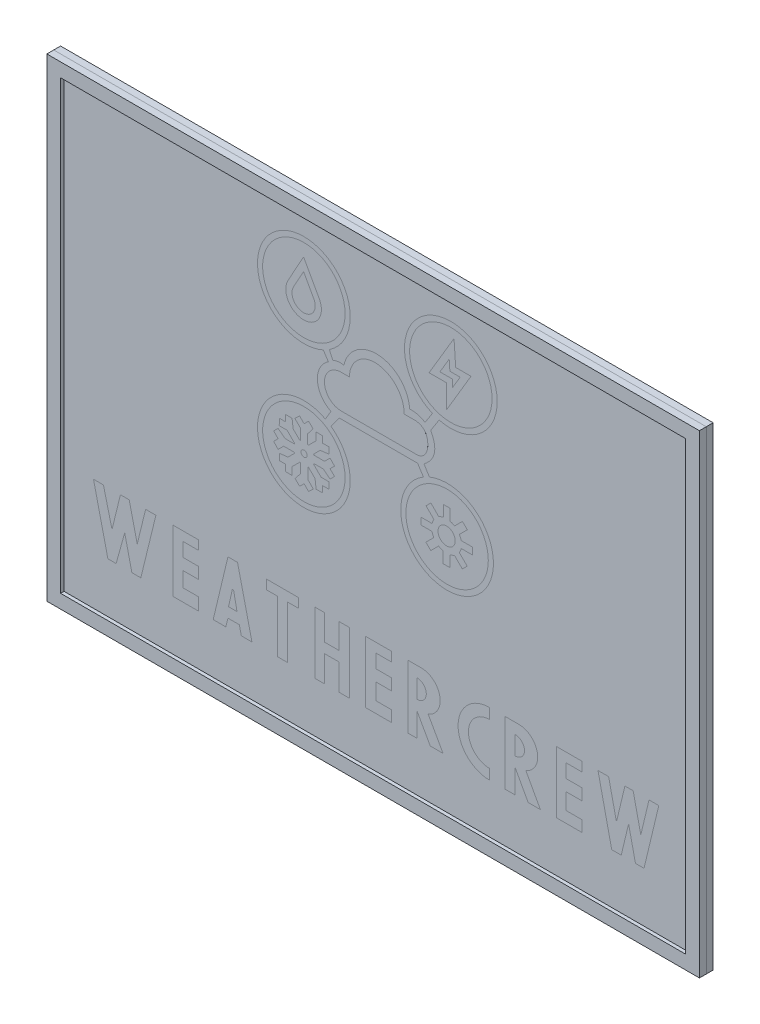
from build123d import *

# Parameters (mm, degrees)
SKETCH2_W              = 95
SKETCH2_H              = 69
BOSS_EXTRUDE1_DEPTH    = 10
SKETCH6_R              = 6.75
SKETCH6_R_2            = 6
CUT_EXTRUDE2_DEPTH     = 2
CUT_EXTRUDE3_DEPTH     = 2
CUT_EXTRUDE4_DEPTH     = 2
CUT_EXTRUDE5_DEPTH     = 2
SKETCH10_R             = 0.450714804
CUT_EXTRUDE6_DEPTH     = 2
SKETCH11_R             = 1.253958972
CUT_EXTRUDE7_DEPTH     = 2
CUT_EXTRUDE8_DEPTH     = 2
CUT_EXTRUDE9_DEPTH     = 2
BOSS_EXTRUDE2_DEPTH    = 2
SKETCH15_W             = 91
SKETCH15_H             = 65
CUT_EXTRUDE10_DEPTH    = 1
SKETCH16_W             = 95
SKETCH16_H             = 69
CUT_EXTRUDE11_DEPTH    = 7.5
SKETCH17_W             = 111.119641026
SKETCH17_H             = 170.888738564
CUT_EXTRUDE12_DEPTH    = 0.5
BOSS_EXTRUDE3_DEPTH    = 1
BOSS_EXTRUDE4_DEPTH    = 1
BOSS_EXTRUDE5_DEPTH    = 1
BOSS_EXTRUDE6_DEPTH    = 1
BOSS_EXTRUDE7_DEPTH    = 1
BOSS_EXTRUDE8_DEPTH    = 1
BOSS_EXTRUDE9_DEPTH    = 1
BOSS_EXTRUDE10_DEPTH   = 1
BOSS_EXTRUDE11_DEPTH   = 1
BOSS_EXTRUDE12_DEPTH   = 1
BOSS_EXTRUDE13_DEPTH   = 1
SKETCH29_R             = 6
BOSS_EXTRUDE15_DEPTH   = 1
BOSS_EXTRUDE16_DEPTH   = 1
BOSS_EXTRUDE16_2_DEPTH = 1
SKETCH30_R             = 1.253958972
BOSS_EXTRUDE16_3_DEPTH = 1
SKETCH30_R_2           = 0.450714804
BOSS_EXTRUDE16_4_DEPTH = 1
SKETCH32_W             = 95
SKETCH32_H             = 69
SKETCH32_W_2           = 91
SKETCH32_H_2           = 65
CUT_EXTRUDE13_DEPTH    = 1
SKETCH33_W             = 95
SKETCH33_H             = 69
SKETCH33_W_2           = 91
SKETCH33_H_2           = 65
BOSS_EXTRUDE18_DEPTH   = 1


with BuildPart() as part:
    # Sketch2 → Boss-Extrude1 (new body)
    with BuildSketch(Plane.XY):
        with Locations((0, 34.5)):
            Rectangle(SKETCH2_W, SKETCH2_H)
    extrude(amount=-BOSS_EXTRUDE1_DEPTH)

    # Sketch6 → Cut-Extrude2 (cut)
    with BuildSketch(Plane.XY):
        with Locations((-10.58381474, 57.43670604)):
            Circle(SKETCH6_R)
        with Locations((-10.58381474, 57.43670604)):
            Circle(SKETCH6_R_2, mode=Mode.SUBTRACT)
        with Locations((10.812308125, 57.43670604)):
            Circle(SKETCH6_R)
        with Locations((10.812308125, 57.43670604)):
            Circle(SKETCH6_R_2, mode=Mode.SUBTRACT)
        with Locations((10.26766318, 36.765254362)):
            Circle(SKETCH6_R)
        with Locations((10.26766318, 36.765254362)):
            Circle(SKETCH6_R_2, mode=Mode.SUBTRACT)
        with Locations((-10.58381474, 36.765254362)):
            Circle(SKETCH6_R)
        with Locations((-10.58381474, 36.765254362)):
            Circle(SKETCH6_R_2, mode=Mode.SUBTRACT)
    extrude(amount=-CUT_EXTRUDE2_DEPTH, mode=Mode.SUBTRACT)

    # Sketch7 → Cut-Extrude3 (cut)
    with BuildSketch(Plane.XY):
        with BuildLine():
            Line((-7.916468347, 51.567956725), (-7.022121124, 50.177096153))
            ThreePointArc((-7.022121124, 50.177096153), (-8.609890443, 47.034119387), (-6.635192926, 44.118663319))
            Line((-6.635192926, 44.118663319), (-7.649707674, 42.416518808))
            Line((-7.649707674, 42.416518808), (-6.804780517, 41.993854271))
            Line((-6.804780517, 41.993854271), (-5.447898407, 43.885946163))
            Line((-5.447898407, 43.885946163), (5.983188142, 43.885946163))
            Line((5.983188142, 43.885946163), (6.916964546, 42.416518808))
            Line((6.916964546, 42.416518808), (7.816448751, 42.808240391))
            Line((7.816448751, 42.808240391), (6.906109538, 44.26728253))
            add(Edge.make_bspline(
                [(7.875539511, 48.976219061), (9.446822692, 46.209997418), (6.906109538, 44.26728253)],
                knots=[0, 0, 0, 1, 1, 1], degree=2))
            Line((7.875539511, 48.976219061), (9.246727766, 51.112726421))
            Line((9.246727766, 51.112726421), (8.288367565, 51.496070502))
            Line((8.288367565, 51.496070502), (7.055214208, 49.569574602))
            ThreePointArc((7.055214208, 49.569574602), (5.981804612, 50.037286065), (4.816091537, 50.147173276))
            ThreePointArc((4.816091537, 50.147173276), (0.341321011, 54.670000608), (-4.760297485, 50.868286907))
            ThreePointArc((-4.760297485, 50.868286907), (-5.575593194, 50.911439955), (-6.362243649, 50.692921444))
            Line((-6.362243649, 50.692921444), (-7.013552418, 52.102384415))
            Line((-7.013552418, 52.102384415), (-7.916468347, 51.567956725))
        make_face()
        with BuildLine():
            Line((-5.143487762, 44.908074053), (5.983188142, 44.908074053))
            add(Edge.make_bspline(
                [(5.743505719, 49.106863126), (6.904367351, 48.955079203), (7.457190704, 48.093692386), (7.475060164, 45.959471108), (6.874484997, 45.026980514), (5.983188142, 44.908074053)],
                knots=[0, 0, 0, 0, 0.494202961, 0.594202961, 1, 1, 1, 1], degree=3))
            Line((5.743505719, 49.106863126), (4.027228665, 49.106863126))
            ThreePointArc((4.027228665, 49.106863126), (2.939757073, 51.995669649), (0.217252122, 53.450236384))
            ThreePointArc((0.217252122, 53.450236384), (-2.691839557, 52.567189889), (-3.946366377, 49.797939455))
            Line((-3.946366377, 49.797939455), (-5.085883019, 49.797939455))
            ThreePointArc((-5.085883019, 49.797939455), (-7.588590109, 47.382150428), (-5.143487762, 44.908074053))
        make_face(mode=Mode.SUBTRACT)
    extrude(amount=-CUT_EXTRUDE3_DEPTH, mode=Mode.SUBTRACT)

    # Sketch8 → Cut-Extrude4 (cut)
    with BuildSketch(Plane.XY):
        with BuildLine():
            Line((-10.623400902, 61.602283424), (-12.888676015, 57.507049576))
            ThreePointArc((-12.888676015, 57.507049576), (-10.606948418, 53.663624053), (-8.371242416, 57.5340012))
            Line((-8.371242416, 57.5340012), (-10.623400902, 61.602283424))
        make_face()
        with BuildLine():
            Line((-10.623087552, 59.74347261), (-12.101131253, 57.071419862))
            ThreePointArc((-12.101131253, 57.071419862), (-10.609986404, 54.563623554), (-9.155844402, 57.09305557))
            Line((-9.155844402, 57.09305557), (-10.623087552, 59.74347261))
        make_face(mode=Mode.SUBTRACT)
    extrude(amount=-CUT_EXTRUDE4_DEPTH, mode=Mode.SUBTRACT)

    # Sketch9 → Cut-Extrude5 (cut)
    with BuildSketch(Plane.XY):
        Polygon((11.276935334, 62.260535198), (7.641940029, 56.131455524), (10.162557211, 56.131455524), (10.162557211, 52.682189907), (13.744486891, 58.731671143), (11.515730646, 58.731671143), align=None)
        Polygon((10.574423806, 59.311678097), (9.222084011, 57.031455524), (11.062557211, 57.031455524), (11.062557211, 55.968655304), (12.165658695, 57.831671143), (10.674574652, 57.831671143), align=None, mode=Mode.SUBTRACT)
    extrude(amount=-CUT_EXTRUDE5_DEPTH, mode=Mode.SUBTRACT)

    # Sketch10 → Cut-Extrude6 (cut)
    with BuildSketch(Plane.XY):
        Polygon((-11.188330045, 38.206118102), (-12.14781198, 39.165600038), (-12.297274909, 40.421092801), (-13.222489633, 40.421092801), (-13.222489633, 39.495878077), (-14.147704357, 39.495878077), (-14.16990948, 38.54845823), (-13.028948449, 38.54845823), (-11.937469183, 37.456978964), (-11.979251198, 37.349405556), (-13.336163564, 37.349405556), (-14.329617261, 38.131486752), (-14.983842866, 37.477261147), (-14.329617261, 36.823035542), (-14.983842866, 36.168809936), (-14.329617261, 35.483181544), (-13.522835979, 36.289962826), (-11.979251198, 36.289962826), (-11.932729657, 36.184352594), (-12.892211593, 35.224870658), (-14.147704357, 35.07540773), (-14.147704357, 34.150193006), (-13.222489633, 34.150193006), (-13.222489633, 33.224978282), (-12.275069785, 33.202773159), (-12.275069785, 34.34373419), (-11.183590519, 35.435213456), (-11.076017111, 35.393431441), (-11.076017111, 34.036519075), (-11.858098308, 33.043065378), (-11.203872702, 32.388839772), (-10.549647097, 33.043065378), (-9.895421492, 32.388839772), (-9.2097931, 33.043065378), (-10.016574382, 33.84984666), (-10.016574382, 35.393431441), (-9.91096415, 35.439952981), (-8.951482214, 34.480471045), (-8.802019285, 33.224978282), (-7.876804562, 33.224978282), (-7.876804562, 34.150193006), (-6.951589838, 34.150193006), (-6.929384714, 35.097612853), (-8.070345745, 35.097612853), (-9.161825011, 36.18909212), (-9.120042997, 36.296665527), (-7.76313063, 36.296665527), (-6.769676933, 35.514584331), (-6.115451328, 36.168809936), (-6.769676933, 36.823035542), (-6.115451328, 37.477261147), (-6.769676933, 38.162889539), (-7.576458215, 37.356108257), (-9.120042997, 37.356108257), (-9.166564537, 37.461718489), (-8.207082601, 38.421200425), (-6.951589838, 38.570663353), (-6.951589838, 39.495878077), (-7.876804562, 39.495878077), (-7.876804562, 40.421092801), (-8.824224409, 40.443297925), (-8.824224409, 39.302336894), (-9.915703675, 38.210857627), (-10.023277083, 38.252639642), (-10.023277083, 39.609552009), (-9.241195887, 40.603005706), (-9.895421492, 41.257231311), (-10.549647097, 40.603005706), (-11.203872702, 41.257231311), (-11.889501095, 40.603005706), (-11.082719813, 39.796224424), (-11.082719813, 38.252639642), align=None)
        with Locations((-10.549647097, 36.823035542)):
            Circle(SKETCH10_R, mode=Mode.SUBTRACT)
    extrude(amount=-CUT_EXTRUDE6_DEPTH, mode=Mode.SUBTRACT)

    # Sketch11 → Cut-Extrude7 (cut)
    with BuildSketch(Plane.XY):
        with BuildLine():
            Line((9.710677124, 40.572413658), (9.710677124, 38.948756586))
            ThreePointArc((9.710677124, 38.948756586), (9.374934304, 38.842969581), (9.060599421, 38.684515445))
            Line((9.060599421, 38.684515445), (7.907826689, 39.837288177))
            Line((7.907826689, 39.837288177), (7.202062449, 39.131523937))
            Line((7.202062449, 39.131523937), (8.350161376, 37.983425011))
            ThreePointArc((8.350161376, 37.983425011), (8.187558059, 37.671216277), (8.077333727, 37.336903956))
            Line((8.077333727, 37.336903956), (6.447066895, 37.336903956))
            Line((6.447066895, 37.336903956), (6.447066895, 36.338802596))
            Line((6.447066895, 36.338802596), (8.070723967, 36.338802596))
            ThreePointArc((8.070723967, 36.338802596), (8.176510972, 36.003059776), (8.334965108, 35.688724894))
            Line((8.334965108, 35.688724894), (7.182192376, 34.535952162))
            Line((7.182192376, 34.535952162), (7.887956616, 33.830187922))
            Line((7.887956616, 33.830187922), (9.036055543, 34.978286848))
            ThreePointArc((9.036055543, 34.978286848), (9.348264276, 34.815683532), (9.682576597, 34.705459199))
            Line((9.682576597, 34.705459199), (9.682576597, 33.075192367))
            Line((9.682576597, 33.075192367), (10.680677957, 33.075192367))
            Line((10.680677957, 33.075192367), (10.680677957, 34.69884944))
            ThreePointArc((10.680677957, 34.69884944), (11.016420777, 34.804636445), (11.330755659, 34.963090581))
            Line((11.330755659, 34.963090581), (12.483528391, 33.810317849))
            Line((12.483528391, 33.810317849), (13.189292631, 34.516082089))
            Line((13.189292631, 34.516082089), (12.041193705, 35.664181015))
            ThreePointArc((12.041193705, 35.664181015), (12.203797021, 35.976389748), (12.314021354, 36.31070207))
            Line((12.314021354, 36.31070207), (13.944288186, 36.31070207))
            Line((13.944288186, 36.31070207), (13.944288186, 37.308803429))
            Line((13.944288186, 37.308803429), (12.320631113, 37.308803429))
            ThreePointArc((12.320631113, 37.308803429), (12.214844109, 37.644546249), (12.056389972, 37.958881132))
            Line((12.056389972, 37.958881132), (13.209162704, 39.111653864))
            Line((13.209162704, 39.111653864), (12.503398464, 39.817418104))
            Line((12.503398464, 39.817418104), (11.355299538, 38.669319177))
            ThreePointArc((11.355299538, 38.669319177), (11.043090805, 38.831922494), (10.708778484, 38.942146827))
            Line((10.708778484, 38.942146827), (10.708778484, 40.572413658))
            Line((10.708778484, 40.572413658), (9.710677124, 40.572413658))
        make_face()
        with Locations((10.19567754, 36.823803013)):
            Circle(SKETCH11_R, mode=Mode.SUBTRACT)
    extrude(amount=-CUT_EXTRUDE7_DEPTH, mode=Mode.SUBTRACT)

    # Sketch12 → Cut-Extrude8 (cut)
    with BuildSketch(Plane.XY):
        Polygon((-39.761913051, 18.281051864), (-41.209949669, 18.281051864), (-39.112793188, 9.293238373), (-37.914418056, 9.293238373), (-36.666110627, 13.787145118), (-35.617532386, 9.293238373), (-34.31929266, 9.293238373), (-32.122271584, 18.281051864), (-33.620240499, 18.281051864), (-34.842571589, 13.280606497), (-36.009342175, 18.281051864), (-37.290264341, 18.281051864), (-38.513605622, 13.276473897), align=None)
        Polygon((-29.625656726, 18.281051864), (-29.625656726, 9.293238373), (-25.930666735, 9.293238373), (-25.930666735, 11.102140866), (-28.177620108, 11.102140866), (-28.177620108, 13.280606497), (-25.930666735, 13.280606497), (-25.930666735, 14.935587953), (-28.177620108, 14.935587953), (-28.177620108, 16.950633546), (-25.930666735, 16.950633546), (-25.930666735, 18.281051864), align=None)
        Polygon((-21.636489178, 18.281051864), (-20.238384858, 18.281051864), (-18.141228376, 9.293238373), (-19.689129589, 9.293238373), (-19.982643634, 10.55115571), (-21.636489178, 10.55115571), (-21.943980083, 9.293238373), (-23.783577957, 9.293238373), align=None)
        Polygon((-15.994139598, 18.281051864), (-15.994139598, 16.923693785), (-14.455277415, 16.923693785), (-14.455277415, 9.293238373), (-12.96046877, 9.293238373), (-12.96046877, 16.923693785), (-11.386985987, 16.923693785), (-11.386985987, 18.281051864), align=None)
        Polygon((-8.995292156, 18.281051864), (-7.602759892, 18.281051864), (-7.602759892, 14.555602195), (-5.478558134, 14.555602195), (-5.478558134, 18.212919256), (-3.920810178, 18.212919256), (-3.920810178, 9.293238373), (-5.478558134, 9.293238373), (-5.478558134, 13.108466079), (-7.602759892, 13.108466079), (-7.602759892, 9.293238373), (-8.995292156, 9.293238373), align=None)
        Polygon((-1.60802373, 18.281051864), (-1.60802373, 9.293238373), (2.181826999, 9.293238373), (2.181826999, 10.907742602), (-0.090131494, 10.907742602), (-0.090131494, 13.280606497), (2.181826999, 13.280606497), (2.181826999, 14.935587953), (-0.090131494, 14.935587953), (-0.090131494, 16.923693785), (2.181826999, 16.923693785), (2.181826999, 18.281051864), align=None)
        Polygon((26.19018732, 18.281051864), (26.19018732, 9.293238373), (29.929334935, 9.293238373), (29.929334935, 10.907742602), (27.573159725, 10.907742602), (27.573159725, 13.280606497), (29.929334935, 13.280606497), (29.929334935, 14.935587953), (27.573159725, 14.935587953), (27.573159725, 16.923693785), (29.929334935, 16.923693785), (29.929334935, 18.281051864), align=None)
        Polygon((32.234288944, 18.281051864), (34.231915752, 9.293238373), (35.614888158, 9.293238373), (36.690533362, 13.787145118), (37.689346766, 9.293238373), (38.9325302, 9.293238373), (41.083820609, 18.281051864), (39.661362974, 18.281051864), (38.464474524, 13.280606497), (37.353078106, 18.281051864), (36.15271076, 18.281051864), (34.923401955, 13.145158441), (33.781900922, 18.281051864), align=None)
    extrude(amount=-CUT_EXTRUDE8_DEPTH, mode=Mode.SUBTRACT)

    # Sketch13 → Cut-Extrude9 (cut)
    with BuildSketch(Plane.XY):
        Polygon((-21.124172407, 14.480713983), (-21.584947988, 12.078098454), (-20.317815141, 12.078098454), (-20.821420634, 14.480713983), align=None)
        with BuildLine():
            Line((4.555561138, 18.350775546), (4.555561138, 9.159008153))
            Line((4.555561138, 9.159008153), (5.877438323, 9.159008153))
            Line((5.877438323, 9.159008153), (5.877438323, 12.628935763))
            Line((5.877438323, 12.628935763), (7.818945438, 9.159008153))
            Line((7.818945438, 9.159008153), (9.677835229, 9.159008153))
            Line((9.677835229, 9.159008153), (7.515249862, 13.024054341))
            ThreePointArc((7.515249862, 13.024054341), (9.217175423, 16.105246622), (6.506475082, 18.350775546))
            Line((6.506475082, 18.350775546), (4.555561138, 18.350775546))
        make_face()
        with BuildLine():
            Line((5.877438323, 16.801110628), (5.877438323, 14.074738934))
            ThreePointArc((5.877438323, 14.074738934), (7.240624169, 15.437924781), (5.877438323, 16.801110628))
        make_face(mode=Mode.SUBTRACT)
        with BuildLine():
            Line((16.452455801, 18.329531122), (16.452455801, 16.801110628))
            ThreePointArc((16.452455801, 16.801110628), (13.37496048, 13.723615307), (16.452455801, 10.646119986))
            Line((16.452455801, 10.646119986), (16.452455801, 9.159008153))
            ThreePointArc((16.452455801, 9.159008153), (11.867194316, 13.744269638), (16.452455801, 18.329531122))
        make_face()
        with BuildLine():
            Line((18.724432212, 9.159008153), (20.170235383, 9.159008153))
            Line((20.170235383, 9.159008153), (20.170235383, 12.628935763))
            Line((20.170235383, 12.628935763), (22.070433836, 9.159008153))
            Line((22.070433836, 9.159008153), (23.846706304, 9.159008153))
            Line((23.846706304, 9.159008153), (21.730133391, 13.024054341))
            ThreePointArc((21.730133391, 13.024054341), (23.410497152, 16.101857347), (20.706415821, 18.334442813))
            Line((20.706415821, 18.334442813), (18.724432212, 18.334442813))
            Line((18.724432212, 18.334442813), (18.724432212, 9.159008153))
        make_face()
        with BuildLine():
            Line((20.170235383, 16.801110628), (20.170235383, 14.074738934))
            ThreePointArc((20.170235383, 14.074738934), (21.53342123, 15.437924781), (20.170235383, 16.801110628))
        make_face(mode=Mode.SUBTRACT)
    extrude(amount=-CUT_EXTRUDE9_DEPTH, mode=Mode.SUBTRACT)

    # Sketch14 → Boss-Extrude2 (add)
    with BuildSketch(Plane.XY.offset(-2)):
        Polygon((-20.994711946, 14.5132433), (-21.548978406, 12.036733588), (-20.31072355, 12.036733588), (-20.817818395, 14.5132433), align=None)
    extrude(amount=BOSS_EXTRUDE2_DEPTH)

    # Sketch15 → Cut-Extrude10 (cut)
    with BuildSketch(Plane.XY):
        with Locations((0, 34.5)):
            Rectangle(SKETCH15_W, SKETCH15_H)
    extrude(amount=-CUT_EXTRUDE10_DEPTH, mode=Mode.SUBTRACT)

    # Sketch16 → Cut-Extrude11 (cut)
    with BuildSketch(Plane(origin=(0, 0, -10), x_dir=(-1, 0, 0), z_dir=(0, 0, -1))):
        with Locations((0, 34.5)):
            Rectangle(SKETCH16_W, SKETCH16_H)
    extrude(amount=-CUT_EXTRUDE11_DEPTH, mode=Mode.SUBTRACT)

    # Sketch17 → Cut-Extrude12 (cut)
    with BuildSketch(Plane.XY):
        Rectangle(SKETCH17_W, SKETCH17_H)
    extrude(amount=-CUT_EXTRUDE12_DEPTH, mode=Mode.SUBTRACT)

    # Sketch32 → Cut-Extrude13 (cut)
    with BuildSketch(Plane.XY.offset(-0.5)):
        with Locations((0, 34.5)):
            Rectangle(SKETCH32_W, SKETCH32_H)
        with Locations((0, 34.5)):
            Rectangle(SKETCH32_W_2, SKETCH32_H_2, mode=Mode.SUBTRACT)
    extrude(amount=-CUT_EXTRUDE13_DEPTH, mode=Mode.SUBTRACT)


with BuildPart() as body_2:
    # Sketch18 → Boss-Extrude3 (new body)
    with BuildSketch(Plane.XY.offset(-2)):
        Polygon((-38.513605622, 13.276473897), (-39.761913051, 18.281051864), (-41.209949669, 18.281051864), (-39.112793188, 9.293238373), (-37.914418056, 9.293238373), (-36.666110627, 13.787145118), (-35.617532386, 9.293238373), (-34.31929266, 9.293238373), (-32.122271584, 18.281051864), (-33.620240499, 18.281051864), (-34.842571589, 13.280606497), (-36.009342175, 18.281051864), (-37.290264341, 18.281051864), align=None)
    extrude(amount=BOSS_EXTRUDE3_DEPTH)


with BuildPart() as body_3:
    # Sketch19 → Boss-Extrude4 (new body)
    with BuildSketch(Plane.XY.offset(-2)):
        Polygon((-25.930666735, 18.281051864), (-29.625656726, 18.281051864), (-29.625656726, 9.293238373), (-25.930666735, 9.293238373), (-25.930666735, 11.102140866), (-28.177620108, 11.102140866), (-28.177620108, 13.280606497), (-25.930666735, 13.280606497), (-25.930666735, 14.935587953), (-28.177620108, 14.935587953), (-28.177620108, 16.950633546), (-25.930666735, 16.950633546), align=None)
    extrude(amount=BOSS_EXTRUDE4_DEPTH)


with BuildPart() as body_4:
    # Sketch20 → Boss-Extrude5 (new body)
    with BuildSketch(Plane.XY.offset(-2)):
        Polygon((-21.636489178, 18.281051864), (-23.783577957, 9.293238373), (-21.943980083, 9.293238373), (-21.636489178, 10.55115571), (-19.982643634, 10.55115571), (-19.689129589, 9.293238373), (-18.141228376, 9.293238373), (-20.238384858, 18.281051864), align=None)
        Polygon((-20.994711946, 14.5132433), (-21.548978406, 12.036733588), (-20.31072355, 12.036733588), (-20.817818395, 14.5132433), align=None, mode=Mode.SUBTRACT)
    extrude(amount=BOSS_EXTRUDE5_DEPTH)


with BuildPart() as body_5:
    # Sketch21 → Boss-Extrude6 (new body)
    with BuildSketch(Plane.XY.offset(-2)):
        Polygon((-11.386985987, 18.281051864), (-15.994139598, 18.281051864), (-15.994139598, 16.923693785), (-14.455277415, 16.923693785), (-14.455277415, 9.293238373), (-12.96046877, 9.293238373), (-12.96046877, 16.923693785), (-11.386985987, 16.923693785), align=None)
    extrude(amount=BOSS_EXTRUDE6_DEPTH)


with BuildPart() as body_6:
    # Sketch22 → Boss-Extrude7 (new body)
    with BuildSketch(Plane.XY.offset(-2)):
        Polygon((-8.995292156, 18.281051864), (-8.995292156, 9.293238373), (-7.602759892, 9.293238373), (-7.602759892, 13.108466079), (-5.478558134, 13.108466079), (-5.478558134, 9.293238373), (-3.920810178, 9.293238373), (-3.920810178, 18.212919256), (-5.478558134, 18.212919256), (-5.478558134, 14.555602195), (-7.602759892, 14.555602195), (-7.602759892, 18.281051864), align=None)
    extrude(amount=BOSS_EXTRUDE7_DEPTH)


with BuildPart() as body_7:
    # Sketch23 → Boss-Extrude8 (new body)
    with BuildSketch(Plane.XY.offset(-2)):
        Polygon((2.181826999, 18.281051864), (-1.60802373, 18.281051864), (-1.60802373, 9.293238373), (2.181826999, 9.293238373), (2.181826999, 10.907742602), (-0.090131494, 10.907742602), (-0.090131494, 13.280606497), (2.181826999, 13.280606497), (2.181826999, 14.935587953), (-0.090131494, 14.935587953), (-0.090131494, 16.923693785), (2.181826999, 16.923693785), align=None)
    extrude(amount=BOSS_EXTRUDE8_DEPTH)


with BuildPart() as body_8:
    # Sketch24 → Boss-Extrude9 (new body)
    with BuildSketch(Plane.XY.offset(-2)):
        with BuildLine():
            Line((5.877438323, 9.159008153), (5.877438323, 12.628935763))
            Line((5.877438323, 12.628935763), (7.818945438, 9.159008153))
            Line((7.818945438, 9.159008153), (9.677835229, 9.159008153))
            Line((9.677835229, 9.159008153), (7.515249862, 13.024054341))
            ThreePointArc((7.515249862, 13.024054341), (9.217175423, 16.105246622), (6.506475082, 18.350775546))
            Line((6.506475082, 18.350775546), (4.555561138, 18.350775546))
            Line((4.555561138, 18.350775546), (4.555561138, 9.159008153))
            Line((4.555561138, 9.159008153), (5.877438323, 9.159008153))
        make_face()
        with BuildLine():
            Line((5.877438323, 16.801110628), (5.877438323, 14.074738934))
            ThreePointArc((5.877438323, 14.074738934), (7.240624169, 15.437924781), (5.877438323, 16.801110628))
        make_face(mode=Mode.SUBTRACT)
    extrude(amount=BOSS_EXTRUDE9_DEPTH)


with BuildPart() as body_9:
    # Sketch25 → Boss-Extrude10 (new body)
    with BuildSketch(Plane.XY.offset(-2)):
        with BuildLine():
            Line((16.452455801, 9.159008153), (16.452455801, 10.646119986))
            ThreePointArc((16.452455801, 10.646119986), (13.37496048, 13.723615307), (16.452455801, 16.801110628))
            Line((16.452455801, 16.801110628), (16.452455801, 18.329531122))
            ThreePointArc((16.452455801, 18.329531122), (11.867194316, 13.744269638), (16.452455801, 9.159008153))
        make_face()
    extrude(amount=BOSS_EXTRUDE10_DEPTH)


with BuildPart() as body_10:
    # Sketch26 → Boss-Extrude11 (new body)
    with BuildSketch(Plane.XY.offset(-2)):
        with BuildLine():
            Line((18.724432212, 18.334442813), (18.724432212, 9.159008153))
            Line((18.724432212, 9.159008153), (20.170235383, 9.159008153))
            Line((20.170235383, 9.159008153), (20.170235383, 12.628935763))
            Line((20.170235383, 12.628935763), (22.070433836, 9.159008153))
            Line((22.070433836, 9.159008153), (23.846706304, 9.159008153))
            Line((23.846706304, 9.159008153), (21.730133391, 13.024054341))
            ThreePointArc((21.730133391, 13.024054341), (23.410497152, 16.101857347), (20.706415821, 18.334442813))
            Line((20.706415821, 18.334442813), (18.724432212, 18.334442813))
        make_face()
        with BuildLine():
            Line((20.170235383, 16.801110628), (20.170235383, 14.074738934))
            ThreePointArc((20.170235383, 14.074738934), (21.53342123, 15.437924781), (20.170235383, 16.801110628))
        make_face(mode=Mode.SUBTRACT)
    extrude(amount=BOSS_EXTRUDE11_DEPTH)


with BuildPart() as body_11:
    # Sketch27 → Boss-Extrude12 (new body)
    with BuildSketch(Plane.XY.offset(-2)):
        Polygon((29.929334935, 18.281051864), (26.19018732, 18.281051864), (26.19018732, 9.293238373), (29.929334935, 9.293238373), (29.929334935, 10.907742602), (27.573159725, 10.907742602), (27.573159725, 13.280606497), (29.929334935, 13.280606497), (29.929334935, 14.935587953), (27.573159725, 14.935587953), (27.573159725, 16.923693785), (29.929334935, 16.923693785), align=None)
    extrude(amount=BOSS_EXTRUDE12_DEPTH)


with BuildPart() as body_12:
    # Sketch28 → Boss-Extrude13 (new body)
    with BuildSketch(Plane.XY.offset(-2)):
        Polygon((38.9325302, 9.293238373), (41.083820609, 18.281051864), (39.661362974, 18.281051864), (38.464474524, 13.280606497), (37.353078106, 18.281051864), (36.15271076, 18.281051864), (34.923401955, 13.145158441), (33.781900922, 18.281051864), (32.234288944, 18.281051864), (34.231915752, 9.293238373), (35.614888158, 9.293238373), (36.690533362, 13.787145118), (37.689346766, 9.293238373), align=None)
    extrude(amount=BOSS_EXTRUDE13_DEPTH)


with BuildPart() as body_13:
    # Sketch29 → Boss-Extrude15 (new body)
    with BuildSketch(Plane.XY.offset(-2)):
        with BuildLine():
            Line((-6.635192926, 44.118663319), (-7.453586334, 42.745569581))
            ThreePointArc((-7.453586334, 42.745569581), (-14.13461302, 31.024668018), (-6.630709979, 42.236585347))
            Line((-6.630709979, 42.236585347), (-5.447898407, 43.885946163))
            Line((-5.447898407, 43.885946163), (5.983188142, 43.885946163))
            Line((5.983188142, 43.885946163), (6.82034084, 42.56856968))
            ThreePointArc((6.82034084, 42.56856968), (13.286271442, 30.727829069), (7.693576945, 43.005172635))
            Line((7.693576945, 43.005172635), (6.906109538, 44.26728253))
            add(Edge.make_bspline(
                [(6.906109538, 44.26728253), (9.446822692, 46.209997418), (7.875539511, 48.976219061)],
                knots=[0, 0, 0, 1, 1, 1], degree=2))
            Line((7.875539511, 48.976219061), (9.112861095, 50.904143006))
            ThreePointArc((9.112861095, 50.904143006), (13.011290206, 63.818475216), (8.126931752, 51.243867133))
            Line((8.126931752, 51.243867133), (7.055214208, 49.569574602))
            ThreePointArc((7.055214208, 49.569574602), (5.981804612, 50.037286065), (4.816091537, 50.147173276))
            ThreePointArc((4.816091537, 50.147173276), (0.341321011, 54.670000608), (-4.760297485, 50.868286907))
            ThreePointArc((-4.760297485, 50.868286907), (-5.575593194, 50.911439955), (-6.362243649, 50.692921444))
            Line((-6.362243649, 50.692921444), (-6.87300454, 51.798232163))
            ThreePointArc((-6.87300454, 51.798232163), (-13.864896339, 63.335604543), (-7.750644077, 51.310072055))
            Line((-7.750644077, 51.310072055), (-7.022121124, 50.177096153))
            ThreePointArc((-7.022121124, 50.177096153), (-8.609890443, 47.034119387), (-6.635192926, 44.118663319))
        make_face()
        with Locations((-10.58381474, 36.765254362)):
            Circle(SKETCH29_R, mode=Mode.SUBTRACT)
        with Locations((10.812308125, 57.43670604)):
            Circle(SKETCH29_R, mode=Mode.SUBTRACT)
        with Locations((-10.58381474, 57.43670604)):
            Circle(SKETCH29_R, mode=Mode.SUBTRACT)
        with Locations((10.26766318, 36.765254362)):
            Circle(SKETCH29_R, mode=Mode.SUBTRACT)
        with BuildLine():
            Line((5.983188142, 44.908074053), (-5.143487762, 44.908074053))
            ThreePointArc((-5.143487762, 44.908074053), (-7.588590109, 47.382150428), (-5.085883019, 49.797939455))
            Line((-5.085883019, 49.797939455), (-3.946366377, 49.797939455))
            ThreePointArc((-3.946366377, 49.797939455), (-2.691839557, 52.567189889), (0.217252122, 53.450236384))
            ThreePointArc((0.217252122, 53.450236384), (2.939757073, 51.995669649), (4.027228665, 49.106863126))
            Line((4.027228665, 49.106863126), (5.743505719, 49.106863126))
            add(Edge.make_bspline(
                [(5.743505719, 49.106863126), (6.904367351, 48.955079203), (7.457190704, 48.093692386), (7.475060164, 45.959471108), (6.874484997, 45.026980514), (5.983188142, 44.908074053)],
                knots=[0, 0, 0, 0, 0.494202961, 0.594202961, 1, 1, 1, 1], degree=3))
        make_face(mode=Mode.SUBTRACT)
    extrude(amount=BOSS_EXTRUDE15_DEPTH)


with BuildPart() as body_14:
    # Sketch30 → Boss-Extrude16 (new body)
    with BuildSketch(Plane.XY.offset(-2)):
        with BuildLine():
            Line((-8.371242416, 57.5340012), (-10.623400902, 61.602283424))
            Line((-10.623400902, 61.602283424), (-12.888676015, 57.507049576))
            ThreePointArc((-12.888676015, 57.507049576), (-10.606948418, 53.663624053), (-8.371242416, 57.5340012))
        make_face()
        with BuildLine():
            Line((-10.623087552, 59.74347261), (-12.101131253, 57.071419862))
            ThreePointArc((-12.101131253, 57.071419862), (-10.609986404, 54.563623554), (-9.155844402, 57.09305557))
            Line((-9.155844402, 57.09305557), (-10.623087552, 59.74347261))
        make_face(mode=Mode.SUBTRACT)
    extrude(amount=BOSS_EXTRUDE16_DEPTH)


with BuildPart() as body_15:
    # Sketch30 → Boss-Extrude16 2 (new body)
    with BuildSketch(Plane.XY.offset(-2)):
        Polygon((11.515730646, 58.731671143), (11.276935334, 62.260535198), (7.641940029, 56.131455524), (10.162557211, 56.131455524), (10.162557211, 52.682189907), (13.744486891, 58.731671143), align=None)
        Polygon((10.574423806, 59.311678097), (9.222084011, 57.031455524), (11.062557211, 57.031455524), (11.062557211, 55.968655304), (12.165658695, 57.831671143), (10.674574652, 57.831671143), align=None, mode=Mode.SUBTRACT)
    extrude(amount=BOSS_EXTRUDE16_2_DEPTH)


with BuildPart() as body_16:
    # Sketch30 → Boss-Extrude16 3 (new body)
    with BuildSketch(Plane.XY.offset(-2)):
        with BuildLine():
            Line((13.209162704, 39.111653864), (12.503398464, 39.817418104))
            Line((12.503398464, 39.817418104), (11.355299538, 38.669319177))
            ThreePointArc((11.355299538, 38.669319177), (11.043090805, 38.831922494), (10.708778484, 38.942146827))
            Line((10.708778484, 38.942146827), (10.708778484, 40.572413658))
            Line((10.708778484, 40.572413658), (9.710677124, 40.572413658))
            Line((9.710677124, 40.572413658), (9.710677124, 38.948756586))
            ThreePointArc((9.710677124, 38.948756586), (9.374934304, 38.842969581), (9.060599421, 38.684515445))
            Line((9.060599421, 38.684515445), (7.907826689, 39.837288177))
            Line((7.907826689, 39.837288177), (7.202062449, 39.131523937))
            Line((7.202062449, 39.131523937), (8.350161376, 37.983425011))
            ThreePointArc((8.350161376, 37.983425011), (8.187558059, 37.671216277), (8.077333727, 37.336903956))
            Line((8.077333727, 37.336903956), (6.447066895, 37.336903956))
            Line((6.447066895, 37.336903956), (6.447066895, 36.338802596))
            Line((6.447066895, 36.338802596), (8.070723967, 36.338802596))
            ThreePointArc((8.070723967, 36.338802596), (8.176510972, 36.003059776), (8.334965108, 35.688724894))
            Line((8.334965108, 35.688724894), (7.182192376, 34.535952162))
            Line((7.182192376, 34.535952162), (7.887956616, 33.830187922))
            Line((7.887956616, 33.830187922), (9.036055543, 34.978286848))
            ThreePointArc((9.036055543, 34.978286848), (9.348264276, 34.815683532), (9.682576597, 34.705459199))
            Line((9.682576597, 34.705459199), (9.682576597, 33.075192367))
            Line((9.682576597, 33.075192367), (10.680677957, 33.075192367))
            Line((10.680677957, 33.075192367), (10.680677957, 34.69884944))
            ThreePointArc((10.680677957, 34.69884944), (11.016420777, 34.804636445), (11.330755659, 34.963090581))
            Line((11.330755659, 34.963090581), (12.483528391, 33.810317849))
            Line((12.483528391, 33.810317849), (13.189292631, 34.516082089))
            Line((13.189292631, 34.516082089), (12.041193705, 35.664181015))
            ThreePointArc((12.041193705, 35.664181015), (12.203797021, 35.976389748), (12.314021354, 36.31070207))
            Line((12.314021354, 36.31070207), (13.944288186, 36.31070207))
            Line((13.944288186, 36.31070207), (13.944288186, 37.308803429))
            Line((13.944288186, 37.308803429), (12.320631113, 37.308803429))
            ThreePointArc((12.320631113, 37.308803429), (12.214844109, 37.644546249), (12.056389972, 37.958881132))
            Line((12.056389972, 37.958881132), (13.209162704, 39.111653864))
        make_face()
        with Locations((10.19567754, 36.823803013)):
            Circle(SKETCH30_R, mode=Mode.SUBTRACT)
    extrude(amount=BOSS_EXTRUDE16_3_DEPTH)


with BuildPart() as body_17:
    # Sketch30 → Boss-Extrude16 4 (new body)
    with BuildSketch(Plane.XY.offset(-2)):
        Polygon((-9.915703675, 38.210857627), (-10.023277083, 38.252639642), (-10.023277083, 39.609552009), (-9.241195887, 40.603005706), (-9.895421492, 41.257231311), (-10.549647097, 40.603005706), (-11.203872702, 41.257231311), (-11.889501095, 40.603005706), (-11.082719813, 39.796224424), (-11.082719813, 38.252639642), (-11.188330045, 38.206118102), (-12.14781198, 39.165600038), (-12.297274909, 40.421092801), (-13.222489633, 40.421092801), (-13.222489633, 39.495878077), (-14.147704357, 39.495878077), (-14.16990948, 38.54845823), (-13.028948449, 38.54845823), (-11.937469183, 37.456978964), (-11.979251198, 37.349405556), (-13.336163564, 37.349405556), (-14.329617261, 38.131486752), (-14.983842866, 37.477261147), (-14.329617261, 36.823035542), (-14.983842866, 36.168809936), (-14.329617261, 35.483181544), (-13.522835979, 36.289962826), (-11.979251198, 36.289962826), (-11.932729657, 36.184352594), (-12.892211593, 35.224870658), (-14.147704357, 35.07540773), (-14.147704357, 34.150193006), (-13.222489633, 34.150193006), (-13.222489633, 33.224978282), (-12.275069785, 33.202773159), (-12.275069785, 34.34373419), (-11.183590519, 35.435213456), (-11.076017111, 35.393431441), (-11.076017111, 34.036519075), (-11.858098308, 33.043065378), (-11.203872702, 32.388839772), (-10.549647097, 33.043065378), (-9.895421492, 32.388839772), (-9.2097931, 33.043065378), (-10.016574382, 33.84984666), (-10.016574382, 35.393431441), (-9.91096415, 35.439952981), (-8.951482214, 34.480471045), (-8.802019285, 33.224978282), (-7.876804562, 33.224978282), (-7.876804562, 34.150193006), (-6.951589838, 34.150193006), (-6.929384714, 35.097612853), (-8.070345745, 35.097612853), (-9.161825011, 36.18909212), (-9.120042997, 36.296665527), (-7.76313063, 36.296665527), (-6.769676933, 35.514584331), (-6.115451328, 36.168809936), (-6.769676933, 36.823035542), (-6.115451328, 37.477261147), (-6.769676933, 38.162889539), (-7.576458215, 37.356108257), (-9.120042997, 37.356108257), (-9.166564537, 37.461718489), (-8.207082601, 38.421200425), (-6.951589838, 38.570663353), (-6.951589838, 39.495878077), (-7.876804562, 39.495878077), (-7.876804562, 40.421092801), (-8.824224409, 40.443297925), (-8.824224409, 39.302336894), align=None)
        with Locations((-10.549647097, 36.823035542)):
            Circle(SKETCH30_R_2, mode=Mode.SUBTRACT)
    extrude(amount=BOSS_EXTRUDE16_4_DEPTH)


with BuildPart() as body_18:
    # Sketch33 → Boss-Extrude18 (new body)
    with BuildSketch(Plane.XY.offset(-1.5)):
        with Locations((0, 34.5)):
            Rectangle(SKETCH33_W, SKETCH33_H)
        with Locations((0, 34.5)):
            Rectangle(SKETCH33_W_2, SKETCH33_H_2, mode=Mode.SUBTRACT)
    extrude(amount=BOSS_EXTRUDE18_DEPTH)


solid = Compound([part.part, body_2.part, body_3.part, body_4.part, body_5.part, body_6.part, body_7.part, body_8.part, body_9.part, body_10.part, body_11.part, body_12.part, body_13.part, body_14.part, body_15.part, body_16.part, body_17.part, body_18.part])
